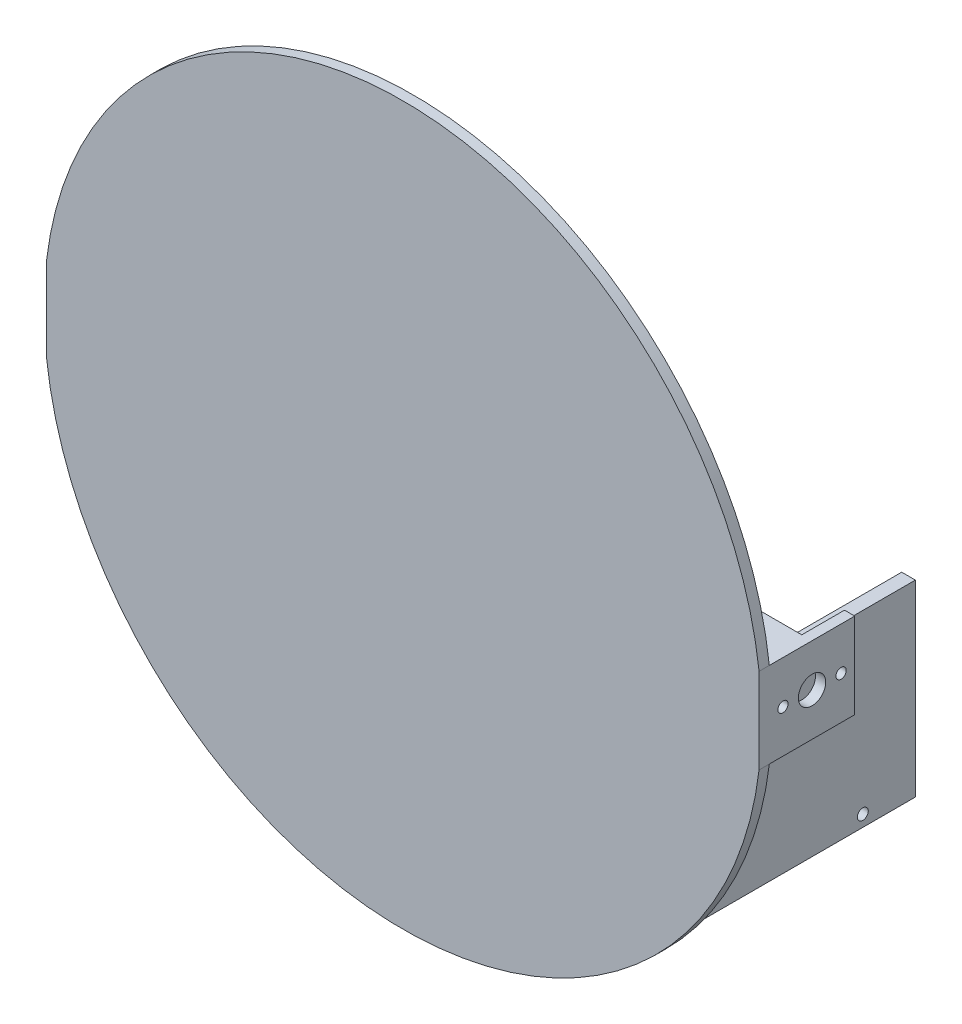
from build123d import *

# Parameters (mm, degrees)
BOSS_EXTRUDE1_DEPTH     = 3
SKETCH1_3_W             = 70
SKETCH1_3_H             = 176
SKETCH1_3_W_2           = 66
SKETCH1_3_H_2           = 172
BOSS_EXTRUDE2_DEPTH     = 5
SKETCH1_4_W             = 66
SKETCH1_4_H             = 25
BOSS_EXTRUDE3_DEPTH     = 25
CUT_EXTRUDE1_START      = -3
SKETCH2_R               = 12.5
SKETCH2_R_2             = 1.5
CUT_EXTRUDE1_DEPTH      = 202.50659462
SKETCH2_4_R             = 1.5
SKETCH2_4_R_2           = 4
CUT_EXTRUDE2_DEPTH      = 1
CUT_EXTRUDE2_DEPTH_BACK = 209.50659462
SKETCH5_R               = 14.5
CUT_EXTRUDE3_DEPTH      = 15.5
SKETCH6_W               = 4
SKETCH6_H               = 55
BOSS_EXTRUDE4_DEPTH     = 70
SKETCH7_R               = 1.6
CUT_EXTRUDE4_DEPTH      = 4


with BuildPart() as part:
    # Sketch1 → Boss-Extrude1 (new body)
    with BuildSketch(Plane.XY):
        with BuildLine():
            ThreePointArc((104.25329731, 12.5), (0, 105), (-104.25329731, 12.5))
            Line((-104.25329731, 12.5), (-104.25329731, -12.5))
            ThreePointArc((-104.25329731, -12.5), (0, -105), (104.25329731, -12.5))
            Line((104.25329731, -12.5), (104.25329731, 12.5))
        make_face()
    extrude(amount=BOSS_EXTRUDE1_DEPTH)

    # Sketch1_3 → Boss-Extrude2 (add)
    with BuildSketch(Plane.XY):
        Rectangle(SKETCH1_3_W, SKETCH1_3_H)
        Rectangle(SKETCH1_3_W_2, SKETCH1_3_H_2, mode=Mode.SUBTRACT)
    extrude(amount=-BOSS_EXTRUDE2_DEPTH)

    # Sketch1_4 → Boss-Extrude3 (add)
    with BuildSketch(Plane.XY):
        with Locations((-71.25329731, 0)):
            Rectangle(SKETCH1_4_W, SKETCH1_4_H)
        with Locations((71.25329731, 0)):
            Rectangle(SKETCH1_4_W, SKETCH1_4_H)
    extrude(amount=-BOSS_EXTRUDE3_DEPTH)

    # Sketch2 → Cut-Extrude1 (cut)
    with BuildSketch(Plane.ZY.offset(104.25329731).offset(CUT_EXTRUDE1_START)):
        with Locations((-12.5, 0)):
            Circle(SKETCH2_R)
        with Locations((-4, 0)):
            Circle(SKETCH2_R_2, mode=Mode.SUBTRACT)
        with Locations((-21, 0)):
            Circle(SKETCH2_R_2, mode=Mode.SUBTRACT)
        with BuildLine():
            ThreePointArc((-25, 2.5e-08), (-21.338834756, 8.838834774), (-12.5, 12.5))
            Line((-12.5, 12.5), (-25, 12.5))
            Line((-25, 12.5), (-25, 2.5e-08))
        make_face()
        with BuildLine():
            ThreePointArc((-12.5, -12.5), (-21.338834774, -8.838834756), (-25, 2.5e-08))
            Line((-25, 2.5e-08), (-25, -12.5))
            Line((-25, -12.5), (-12.5, -12.5))
        make_face()
    extrude(amount=-CUT_EXTRUDE1_DEPTH, mode=Mode.SUBTRACT)


with BuildPart() as cut_extrude1_piece_1:
    # of the 3 separate pieces the step leaves, piece 1, a body of its own (cut_extrude1_pieces)
    add(part.part.solids().sort_by_distance((104.25329731, -12.5, 0))[0])


with BuildPart() as cut_extrude1_piece_2:
    # of the 3 separate pieces the step leaves, piece 2, a body of its own (cut_extrude1_pieces)
    add(part.part.solids().sort_by_distance((-35, -1.118033989, -5))[0])


with BuildPart() as cut_extrude1_piece_3:
    # of the 3 separate pieces the step leaves, piece 3, a body of its own (cut_extrude1_pieces)
    add(part.part.solids().sort_by_distance((35, 1.118033989, -5))[0])


with BuildPart() as cut_extrude2_tool:
    # Sketch2_4 → Cut-Extrude2 (new, two sides)
    with BuildSketch(Plane.ZY.offset(104.25329731)) as cut_extrude2_sk:
        with Locations((-21, 0)):
            Circle(SKETCH2_4_R)
        with Locations((-4, 0)):
            Circle(SKETCH2_4_R)
        with Locations((-12.5, 0)):
            Circle(SKETCH2_4_R_2)
    extrude(amount=CUT_EXTRUDE2_DEPTH)
    extrude(cut_extrude2_sk.sketch, amount=-CUT_EXTRUDE2_DEPTH_BACK)


with BuildPart() as cut_extrude1_piece_1_1:
    add(cut_extrude1_piece_1.part)

    # Cut-Extrude2: cut by cut_extrude2_tool
    add(cut_extrude2_tool.part, mode=Mode.SUBTRACT)

    # Sketch4 one side → Revolve1 (revolve)
    with BuildSketch(Plane(origin=(0, 0, 0), x_dir=(0, 0, -1), z_dir=(1, 0, 0))):
        with BuildLine():
            Line((-17.5, 90.5), (-3, 90.5))
            Line((-3, 90.5), (-3, 105))
            ThreePointArc((-3, 105), (-13.253048327, 100.753048327), (-17.5, 90.5))
        make_face()
    revolve(axis=Axis((0, 90.5, 17.5), (0, 0, -1)))

    # Sketch4_4 one side → Revolve2 (revolve)
    with BuildSketch(Plane(origin=(0, 0, 0), x_dir=(0, 0, -1), z_dir=(1, 0, 0))):
        with BuildLine():
            Line((-17.5, -90.5), (-3, -90.5))
            Line((-3, -90.5), (-3, -76))
            ThreePointArc((-3, -76), (-13.253048327, -80.246951673), (-17.5, -90.5))
        make_face()
    revolve(axis=Axis((0, -90.5, 17.5), (0, 0, -1)))

    # Sketch5 → Cut-Extrude3 (cut, through all)
    with BuildSketch(Plane.XY.offset(3)):
        with Locations((0, -90.5)):
            Circle(SKETCH5_R)
        with Locations((0, 90.5)):
            Circle(SKETCH5_R)
    extrude(amount=CUT_EXTRUDE3_DEPTH, mode=Mode.SUBTRACT)

    # Sketch6 → Boss-Extrude4 (add)
    with BuildSketch(Plane(origin=(0, 0, 0), x_dir=(-1, 0, 0), z_dir=(0, 0, -1))):
        with Locations((-75, -42)):
            Rectangle(SKETCH6_W, SKETCH6_H)
    extrude(amount=BOSS_EXTRUDE4_DEPTH)

    # Sketch7 → Cut-Extrude4 (cut)
    with BuildSketch(Plane(origin=(77, 0, 0), x_dir=(0, 0, -1), z_dir=(1, 0, 0))):
        with Locations((2.54, -33.09)):
            Circle(SKETCH7_R)
        with Locations((54.61, -66.13)):
            Circle(SKETCH7_R)
    extrude(amount=-CUT_EXTRUDE4_DEPTH, mode=Mode.SUBTRACT)


with BuildPart() as cut_extrude1_piece_2_1:
    add(cut_extrude1_piece_2.part)

    # Cut-Extrude2: cut by cut_extrude2_tool
    add(cut_extrude2_tool.part, mode=Mode.SUBTRACT)


with BuildPart() as cut_extrude1_piece_3_1:
    add(cut_extrude1_piece_3.part)

    # Cut-Extrude2: cut by cut_extrude2_tool
    add(cut_extrude2_tool.part, mode=Mode.SUBTRACT)


solid = cut_extrude1_piece_1_1.part
